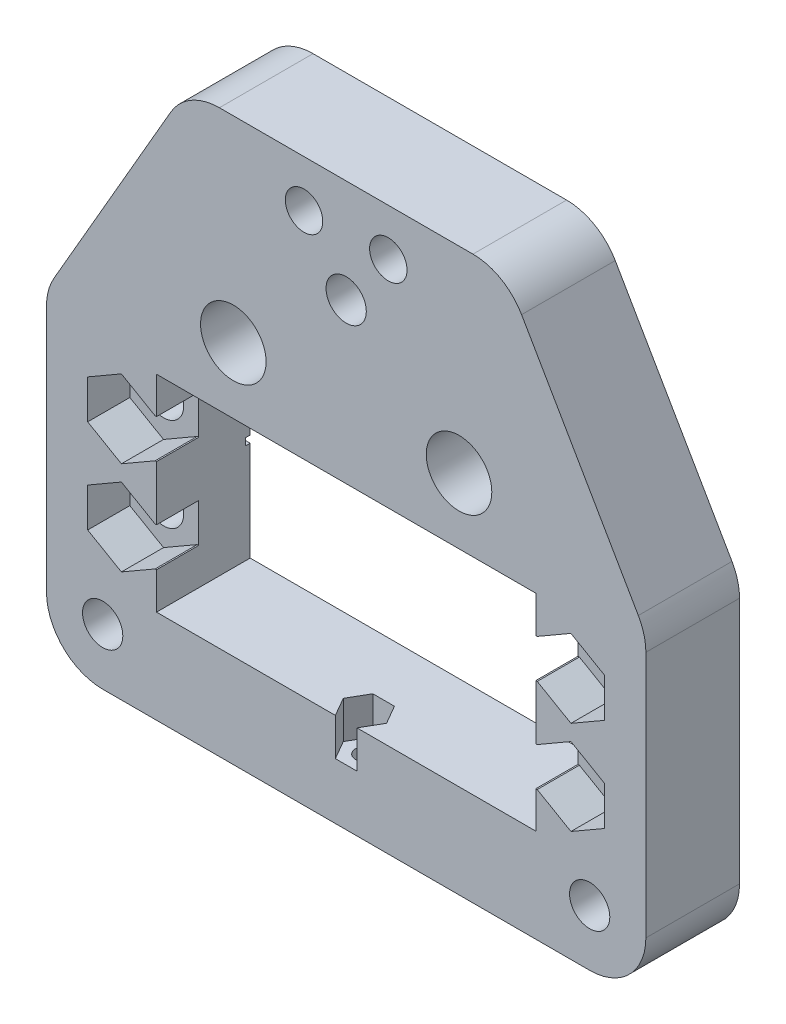
from build123d import *

# Parameters (mm, degrees)
EXTRUDE_1_DEPTH           = 10
FILLET_1_R                = 6
SKETCH_2_W                = 40.5
SKETCH_2_H                = 22
CUT_EXTRUDE_1_DEPTH       = 89.294960219
HOLE_WIZARD_4_0_1_D       = 4
HOLE_WIZARD_4_0_1_DEPTH   = 6
HOLE_WIZARD_4_0_1_TIP     = 1.201721238
HOLE_WIZARD_7_0_7_1_D     = 7
HOLE_WIZARD_7_0_7_1_DEPTH = 6
HOLE_WIZARD_7_0_7_1_TIP   = 2.103012167
HOLE_WIZARD_M41_D         = 4.3
CUT_EXTRUDE_4_DEPTH       = 4.5
HOLE_WIZARD_M42_D         = 4.3
CUT_EXTRUDE_7_DEPTH       = 3.2
SKETCH_19_W               = 4.5
SKETCH_19_H               = 4.156921938
CUT_EXTRUDE_13_DEPTH      = 0.15
SKETCH_21_W               = 4.5
SKETCH_21_H               = 4.156921938
CUT_EXTRUDE_14_DEPTH      = 0.15
SKETCH_22_W               = 4.5
SKETCH_22_H               = 4.156921938
CUT_EXTRUDE_15_DEPTH      = 0.15
SKETCH_23_W               = 4.5
SKETCH_23_H               = 4.156921938
CUT_EXTRUDE_16_DEPTH      = 0.15
CUT_EXTRUDE_17_DEPTH      = 4
HOLE_WIZARD_M2_21_D       = 2
HOLE_WIZARD_M2_21_DEPTH   = 10
HOLE_WIZARD_M2_21_TIP     = 0.600860619
CUT_EXTRUDE_19_DEPTH      = 0.375
CUT_EXTRUDE_20_DEPTH      = 0.375


with BuildPart() as part:
    # Эскиз1 → Бобышка-Вытянуть1 (new body)
    with BuildSketch(Plane.XY):
        Polygon((0, 0), (64, 0), (64, 34.019237886), (49, 60), (15, 60), (0, 34.02), align=None)
    extrude(amount=EXTRUDE_1_DEPTH)

    # Скругление1
    fillet_1_edges = [part.edges().sort_by_distance(p)[0] for p in [
        (49, 60, 5),
        (15, 60, 5),
        (0, 34.02, 5),
        (0, 0, 5),
        (64, 34.019237886, 5),
        (64, 0, 5),
    ]]
    fillet(fillet_1_edges, radius=FILLET_1_R)

    # Эскиз2 → Вырез-Вытянуть1 (cut, through all)
    with BuildSketch(Plane.XY.offset(10)):
        with Locations((32, 21)):
            Rectangle(SKETCH_2_W, SKETCH_2_H)
    extrude(amount=-CUT_EXTRUDE_1_DEPTH, mode=Mode.SUBTRACT)

    # Отверстия под штифты Ø4.0 мм1
    with Locations(Plane.XY.offset(10)):
        with Locations((27.499949191, 55), (36.5, 55)):
            Hole(HOLE_WIZARD_4_0_1_D / 2, depth=HOLE_WIZARD_4_0_1_DEPTH)
            with Locations((0, 0, -(HOLE_WIZARD_4_0_1_DEPTH + HOLE_WIZARD_4_0_1_TIP / 2))):  # 118° drill point
                Cone(0, HOLE_WIZARD_4_0_1_D / 2, HOLE_WIZARD_4_0_1_TIP, mode=Mode.SUBTRACT)

    # Диаметр отверстия Ø7.0 (7)1
    with Locations(Plane.XY.offset(10)):
        with Locations((19.949949191, 39), (44.05, 39)):
            Hole(HOLE_WIZARD_7_0_7_1_D / 2, depth=HOLE_WIZARD_7_0_7_1_DEPTH)
            with Locations((0, 0, -(HOLE_WIZARD_7_0_7_1_DEPTH + HOLE_WIZARD_7_0_7_1_TIP / 2))):  # 118° drill point
                Cone(0, HOLE_WIZARD_7_0_7_1_D / 2, HOLE_WIZARD_7_0_7_1_TIP, mode=Mode.SUBTRACT)

    # Сверло под метчик  спиральное M41 (through all)
    with Locations(Plane.XY.offset(10)):
        with Locations((56, 26), (56, 16), (8, 26), (8, 16)):
            Hole(HOLE_WIZARD_M41_D / 2)

    # Эскиз9 → Вырез-Вытянуть4 (cut)
    with BuildSketch(Plane(origin=(0, 0, 10), x_dir=(-1, 0, 0), z_dir=(0, 0, -1))):
        Polygon((-56, 30.156921938), (-59.6, 28.078460969), (-59.6, 23.921539031), (-56, 21.843078062), (-52.4, 23.921539031), (-52.4, 28.078460969), align=None)
        Polygon((-56, 20.156921938), (-59.6, 18.078460969), (-59.6, 13.921539031), (-56, 11.843078062), (-52.4, 13.921539031), (-52.4, 18.078460969), align=None)
        Polygon((-8, 30.156921938), (-11.6, 28.078460969), (-11.6, 23.921539031), (-8, 21.843078062), (-4.4, 23.921539031), (-4.4, 28.078460969), align=None)
        Polygon((-8, 20.156921938), (-11.6, 18.078460969), (-11.6, 13.921539031), (-8, 11.843078062), (-4.4, 13.921539031), (-4.4, 18.078460969), align=None)
    extrude(amount=CUT_EXTRUDE_4_DEPTH, mode=Mode.SUBTRACT)

    # Сверло под метчик  спиральное M42 (through all)
    with Locations(Plane.XY.offset(10)):
        with Locations((32, 49), (6, 6), (58, 6)):
            Hole(HOLE_WIZARD_M42_D / 2)

    # Эскиз18 → Вырез-Вытянуть7 (cut)
    with BuildSketch(Plane(origin=(0, 0, 0), x_dir=(-1, 0, 0), z_dir=(0, 0, -1))):
        Polygon((-32, 53.156921938), (-35.6, 51.078460969), (-35.6, 46.921539031), (-32, 44.843078062), (-28.4, 46.921539031), (-28.4, 51.078460969), align=None)
        Polygon((-58, 10.156921938), (-61.6, 8.078460969), (-61.6, 3.921539031), (-58, 1.843078062), (-54.4, 3.921539031), (-54.4, 8.078460969), align=None)
        Polygon((-6, 10.156921938), (-9.6, 8.078460969), (-9.6, 3.921539031), (-6, 1.843078062), (-2.4, 3.921539031), (-2.4, 8.078460969), align=None)
    extrude(amount=-CUT_EXTRUDE_7_DEPTH, mode=Mode.SUBTRACT)

    # Эскиз19 → Вырез-Вытянуть13 (cut)
    with BuildSketch(Plane.ZY.offset(-52.25)):
        with Locations((7.75, 26)):
            Rectangle(SKETCH_19_W, SKETCH_19_H)
    extrude(amount=-CUT_EXTRUDE_13_DEPTH, mode=Mode.SUBTRACT)

    # Эскиз21 → Вырез-Вытянуть14 (cut)
    with BuildSketch(Plane(origin=(11.75, 0, 0), x_dir=(0, 0, -1), z_dir=(1, 0, 0))):
        with Locations((-7.75, 26)):
            Rectangle(SKETCH_21_W, SKETCH_21_H)
    extrude(amount=-CUT_EXTRUDE_14_DEPTH, mode=Mode.SUBTRACT)

    # Эскиз22 → Вырез-Вытянуть15 (cut)
    with BuildSketch(Plane.ZY.offset(-52.25)):
        with Locations((7.75, 16)):
            Rectangle(SKETCH_22_W, SKETCH_22_H)
    extrude(amount=-CUT_EXTRUDE_15_DEPTH, mode=Mode.SUBTRACT)

    # Эскиз23 → Вырез-Вытянуть16 (cut)
    with BuildSketch(Plane(origin=(11.75, 0, 0), x_dir=(0, 0, -1), z_dir=(1, 0, 0))):
        with Locations((-7.75, 16)):
            Rectangle(SKETCH_23_W, SKETCH_23_H)
    extrude(amount=-CUT_EXTRUDE_16_DEPTH, mode=Mode.SUBTRACT)

    # Эскиз12 → Вырез-Вытянуть17 (cut)
    with BuildSketch(Plane(origin=(0, 10, 0), x_dir=(1, 0, 0), z_dir=(0, 1, 0))):
        Polygon((34.309375673, -8), (33.154675134, -6), (30.845274057, -6), (29.690573519, -8), (30.845274057, -10), (33.154675134, -10), align=None)
    extrude(amount=-CUT_EXTRUDE_17_DEPTH, mode=Mode.SUBTRACT)

    # Сверло под метчик  спиральное M2.21
    with Locations(Plane(origin=(0, 0, 0), x_dir=(-1, 0, 0), z_dir=(0, -1, 0))):
        with Locations((-32, -8)):
            Hole(HOLE_WIZARD_M2_21_D / 2, depth=HOLE_WIZARD_M2_21_DEPTH)
            with Locations((0, 0, -(HOLE_WIZARD_M2_21_DEPTH + HOLE_WIZARD_M2_21_TIP / 2))):  # 118° drill point
                Cone(0, HOLE_WIZARD_M2_21_D / 2, HOLE_WIZARD_M2_21_TIP, mode=Mode.SUBTRACT)

    # Эскиз29 → Вырез-Вытянуть19 (cut, symmetric)
    with BuildSketch(Plane(origin=(0, 21, 0), x_dir=(1, 0, 0), z_dir=(0, 1, 0))):
        Polygon((5.75, 0), (12.75, 0), (12.75, -0.612420645), align=None)
    extrude(amount=CUT_EXTRUDE_19_DEPTH, both=True, mode=Mode.SUBTRACT)

    # Эскиз29<3> → Вырез-Вытянуть20 (cut, symmetric)
    with BuildSketch(Plane(origin=(0, 21, 0), x_dir=(1, 0, 0), z_dir=(0, 1, 0))):
        Polygon((51.25, 0), (51.25, -0.612420645), (58.25, 0), align=None)
    extrude(amount=CUT_EXTRUDE_20_DEPTH, both=True, mode=Mode.SUBTRACT)


solid = part.part
